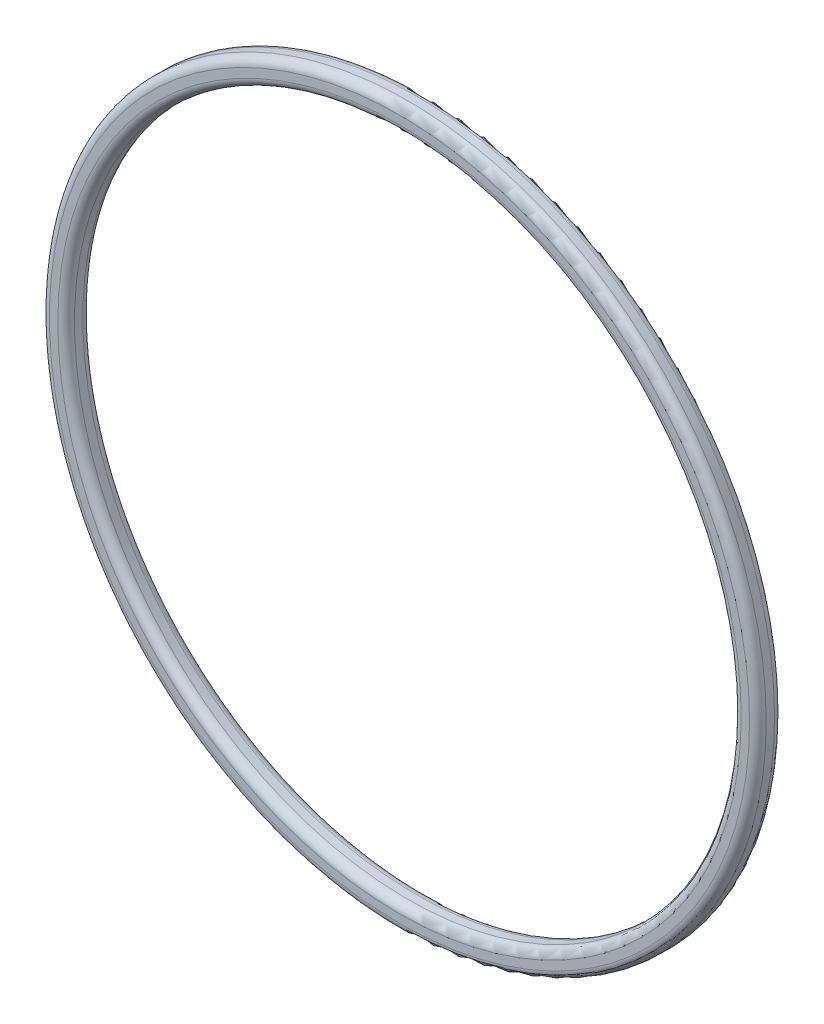
from build123d import *

# Parameters (mm, degrees)
SCHIZZO1_R                   = 43
SCHIZZO1_R_2                 = 40
ESTRUSIONE_ESTRUSIONE1_DEPTH = 3
RACCORDO1_R                  = 1


with BuildPart() as part:
    # Schizzo1 → Estrusione-Estrusione1 (new body)
    with BuildSketch(Plane.XY):
        Circle(SCHIZZO1_R)
        Circle(SCHIZZO1_R_2, mode=Mode.SUBTRACT)
    extrude(amount=ESTRUSIONE_ESTRUSIONE1_DEPTH)

    # Raccordo1
    raccordo1_edges = [part.edges().sort_by_distance(p)[0] for p in [
        (-43, 0, 0),
        (-43, 0, 3),
        (-40, 0, 0),
        (-40, 0, 3),
    ]]
    fillet(raccordo1_edges, radius=RACCORDO1_R)


solid = part.part
